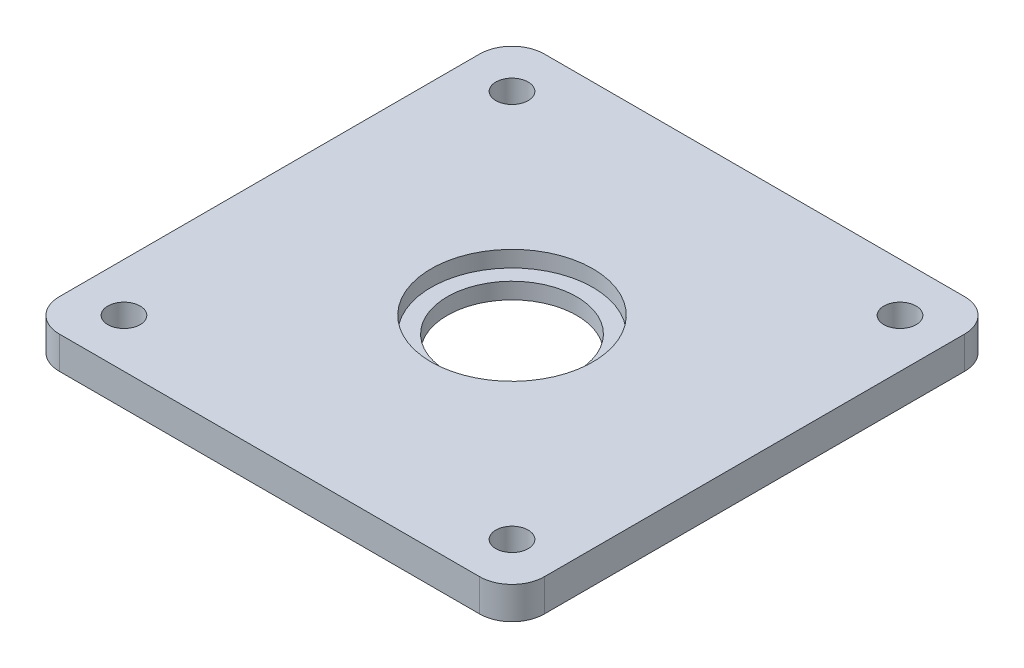
from build123d import *

# Parameters (mm, degrees)
SKETCH1_R           = 10.16
SKETCH1_R_2         = 2.54
BOSS_EXTRUDE1_DEPTH = 5.08
SKETCH2_R           = 12.7
CUT_EXTRUDE1_DEPTH  = 2.54


with BuildPart() as part:
    # Sketch1 → Boss-Extrude1 (new body)
    with BuildSketch(Plane(origin=(0, 0, 0), x_dir=(1, 0, 0), z_dir=(0, 1, 0))):
        with BuildLine():
            Line((-33.02, -38.1), (33.02, -38.1))
            ThreePointArc((33.02, -38.1), (36.612102448, -36.612102448), (38.1, -33.02))
            Line((38.1, -33.02), (38.1, 33.02))
            ThreePointArc((38.1, 33.02), (36.612102448, 36.612102448), (33.02, 38.1))
            Line((33.02, 38.1), (-33.02, 38.1))
            ThreePointArc((-33.02, 38.1), (-36.612102448, 36.612102448), (-38.1, 33.02))
            Line((-38.1, 33.02), (-38.1, -33.02))
            ThreePointArc((-38.1, -33.02), (-36.612102448, -36.612102448), (-33.02, -38.1))
        make_face()
        Circle(SKETCH1_R, mode=Mode.SUBTRACT)
        with Locations((-30.48, 30.48)):
            Circle(SKETCH1_R_2, mode=Mode.SUBTRACT)
        with Locations((30.48, 30.48)):
            Circle(SKETCH1_R_2, mode=Mode.SUBTRACT)
        with Locations((30.48, -30.48)):
            Circle(SKETCH1_R_2, mode=Mode.SUBTRACT)
        with Locations((-30.48, -30.48)):
            Circle(SKETCH1_R_2, mode=Mode.SUBTRACT)
    extrude(amount=BOSS_EXTRUDE1_DEPTH)

    # Sketch2 → Cut-Extrude1 (cut)
    with BuildSketch(Plane(origin=(0, 5.08, 0), x_dir=(1, 0, 0), z_dir=(0, 1, 0))):
        Circle(SKETCH2_R)
    extrude(amount=-CUT_EXTRUDE1_DEPTH, mode=Mode.SUBTRACT)


solid = part.part
